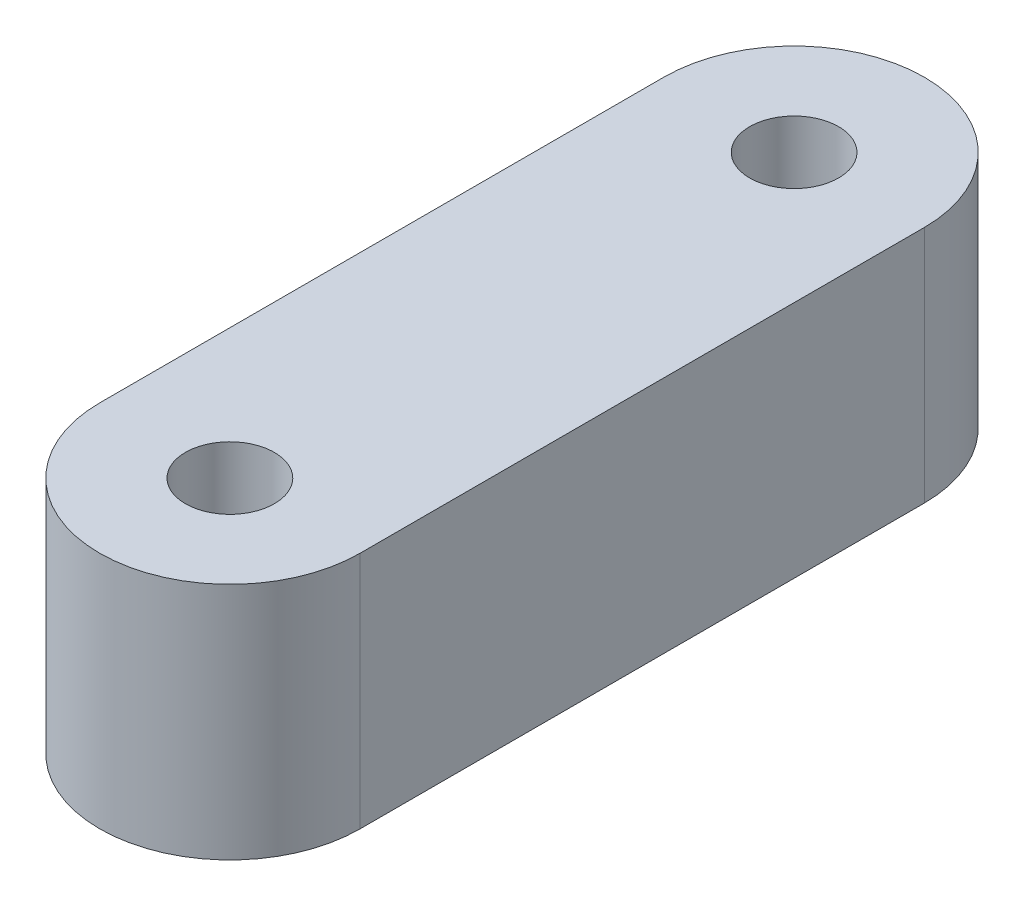
from build123d import *

# Parameters (mm, degrees)
EXTRUDE_1_DEPTH     = 11
SKETCH_2_R          = 2.05
CUT_EXTRUDE_1_DEPTH = 12
SKETCH_3_R          = 3.1
CUT_EXTRUDE_2_DEPTH = 10
EXTRUDE_3_DEPTH     = 10


with BuildPart() as part:
    # 草图1 → 凸台-拉伸1 (new body)
    with BuildSketch(Plane(origin=(0, 0, 0), x_dir=(1, 0, 0), z_dir=(0, 1, 0))):
        with BuildLine():
            Line((-6, -13), (-6, 13))
            ThreePointArc((-6, 13), (0, 19), (6, 13))
            Line((6, 13), (6, -13))
            ThreePointArc((6, -13), (0, -19), (-6, -13))
        make_face()
    extrude(amount=EXTRUDE_1_DEPTH)

    # 草图2 → 切除-拉伸1 (cut, through all)
    with BuildSketch(Plane(origin=(0, 11, 0), x_dir=(1, 0, 0), z_dir=(0, 1, 0))):
        with Locations((0, 13)):
            Circle(SKETCH_2_R)
        with Locations((0, -13)):
            Circle(SKETCH_2_R)
    extrude(amount=-CUT_EXTRUDE_1_DEPTH, mode=Mode.SUBTRACT)

    # 草图3 → 切除-拉伸2 (cut)
    with BuildSketch(Plane.ZY.offset(6)):
        with Locations((0, 5.5)):
            Circle(SKETCH_3_R)
    extrude(amount=-CUT_EXTRUDE_2_DEPTH, mode=Mode.SUBTRACT)

    # 草图4 → 凸台-拉伸3 (add)
    with BuildSketch(Plane.ZY.offset(6)):
        with BuildLine():
            Line((3.146029243, 3.75), (-3.146029243, 3.75))
            ThreePointArc((-3.146029243, 3.75), (0, 1.9), (3.146029243, 3.75))
        make_face()
    extrude(amount=-EXTRUDE_3_DEPTH)


solid = part.part
